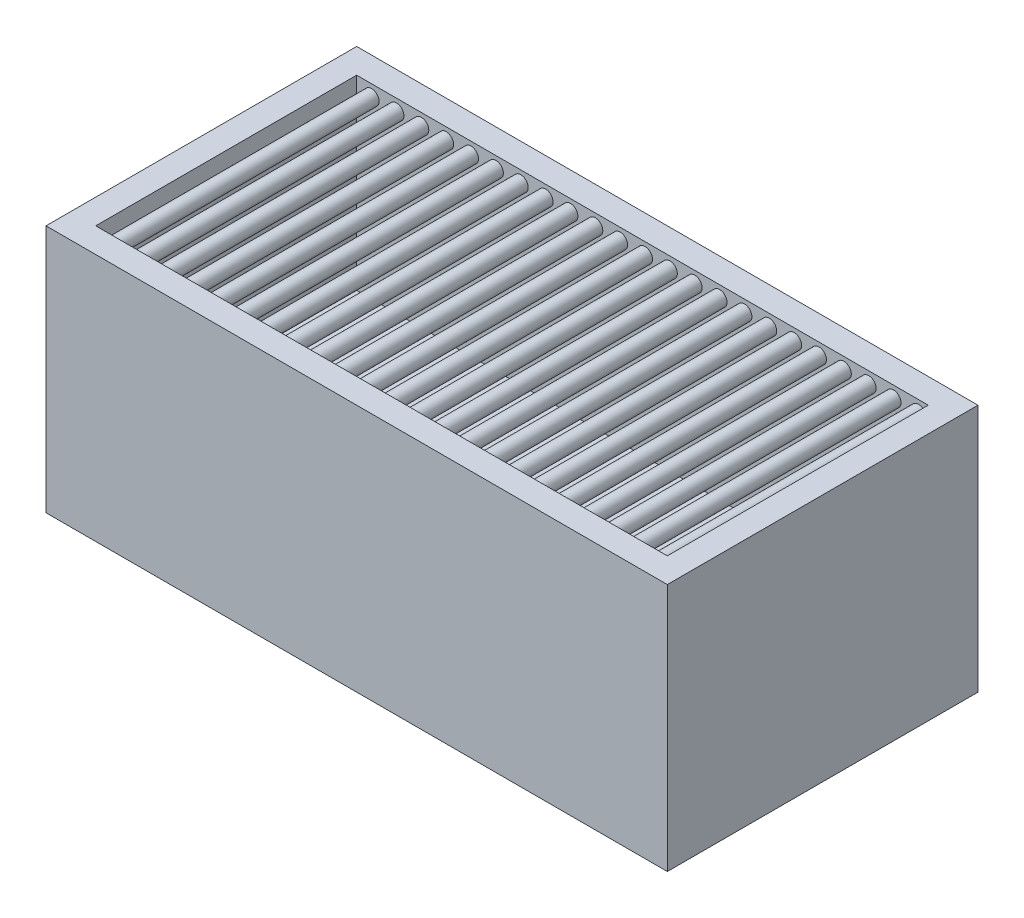
from build123d import *

# Parameters (mm, degrees)
SKETCH1_W           = 50
SKETCH1_H           = 20
BOSS_EXTRUDE1_DEPTH = 12.5
CUT_EXTRUDE1_START  = 20
SKETCH2_W           = 46
SKETCH2_H           = 21
CUT_EXTRUDE1_DEPTH  = 15
BOSS_EXTRUDE2_START = -10.5
SKETCH3_R           = 0.6
BOSS_EXTRUDE2_DEPTH = 21


with BuildPart() as part:
    # Sketch1 → Boss-Extrude1 (new body, symmetric)
    with BuildSketch(Plane.XY):
        with Locations((0, 10)):
            Rectangle(SKETCH1_W, SKETCH1_H)
    extrude(amount=BOSS_EXTRUDE1_DEPTH, both=True)

    # Sketch2 → Cut-Extrude1 (cut)
    with BuildSketch(Plane(origin=(0, 0, 0), x_dir=(1, 0, 0), z_dir=(0, 1, 0)).offset(CUT_EXTRUDE1_START)):
        Rectangle(SKETCH2_W, SKETCH2_H)
    extrude(amount=-CUT_EXTRUDE1_DEPTH, mode=Mode.SUBTRACT)

    # Sketch3 → Boss-Extrude2 (add)
    with BuildSketch(Plane.XY.offset(BOSS_EXTRUDE2_START)):
        with Locations(Location((-21.794964152, 19.065143556, 0), (0, 0, 180))):  # turned: the seam where the file's is
            Circle(SKETCH3_R)
        with Locations(Location((-19.794964152, 19.065143556, 0), (0, 0, 180))):  # turned: the seam where the file's is
            Circle(SKETCH3_R)
        with Locations(Location((-17.794964152, 19.065143556, 0), (0, 0, 180))):  # turned: the seam where the file's is
            Circle(SKETCH3_R)
        with Locations(Location((-15.794964152, 19.065143556, 0), (0, 0, 180))):  # turned: the seam where the file's is
            Circle(SKETCH3_R)
        with Locations(Location((-13.794964152, 19.065143556, 0), (0, 0, 180))):  # turned: the seam where the file's is
            Circle(SKETCH3_R)
        with Locations(Location((-11.794964152, 19.065143556, 0), (0, 0, 180))):  # turned: the seam where the file's is
            Circle(SKETCH3_R)
        with Locations(Location((-9.794964152, 19.065143556, 0), (0, 0, 180))):  # turned: the seam where the file's is
            Circle(SKETCH3_R)
        with Locations(Location((-7.794964152, 19.065143556, 0), (0, 0, 180))):  # turned: the seam where the file's is
            Circle(SKETCH3_R)
        with Locations(Location((-5.794964152, 19.065143556, 0), (0, 0, 180))):  # turned: the seam where the file's is
            Circle(SKETCH3_R)
        with Locations(Location((-3.794964152, 19.065143556, 0), (0, 0, 180))):  # turned: the seam where the file's is
            Circle(SKETCH3_R)
        with Locations(Location((-1.794964152, 19.065143556, 0), (0, 0, 180))):  # turned: the seam where the file's is
            Circle(SKETCH3_R)
        with Locations(Location((0.205035848, 19.065143556, 0), (0, 0, 180))):  # turned: the seam where the file's is
            Circle(SKETCH3_R)
        with Locations(Location((2.205035848, 19.065143556, 0), (0, 0, 180))):  # turned: the seam where the file's is
            Circle(SKETCH3_R)
        with Locations(Location((4.205035848, 19.065143556, 0), (0, 0, 180))):  # turned: the seam where the file's is
            Circle(SKETCH3_R)
        with Locations(Location((6.205035848, 19.065143556, 0), (0, 0, 180))):  # turned: the seam where the file's is
            Circle(SKETCH3_R)
        with Locations(Location((8.205035848, 19.065143556, 0), (0, 0, 180))):  # turned: the seam where the file's is
            Circle(SKETCH3_R)
        with Locations(Location((10.205035848, 19.065143556, 0), (0, 0, 180))):  # turned: the seam where the file's is
            Circle(SKETCH3_R)
        with Locations(Location((12.205035848, 19.065143556, 0), (0, 0, 180))):  # turned: the seam where the file's is
            Circle(SKETCH3_R)
        with Locations(Location((14.205035848, 19.065143556, 0), (0, 0, 180))):  # turned: the seam where the file's is
            Circle(SKETCH3_R)
        with Locations(Location((16.205035848, 19.065143556, 0), (0, 0, 180))):  # turned: the seam where the file's is
            Circle(SKETCH3_R)
        with Locations(Location((18.205035848, 19.065143556, 0), (0, 0, 180))):  # turned: the seam where the file's is
            Circle(SKETCH3_R)
        with Locations(Location((20.205035848, 19.065143556, 0), (0, 0, 180))):  # turned: the seam where the file's is
            Circle(SKETCH3_R)
        with Locations(Location((22.205035848, 19.065143556, 0), (0, 0, 180))):  # turned: the seam where the file's is
            Circle(SKETCH3_R)
    extrude(amount=BOSS_EXTRUDE2_DEPTH)


solid = part.part
